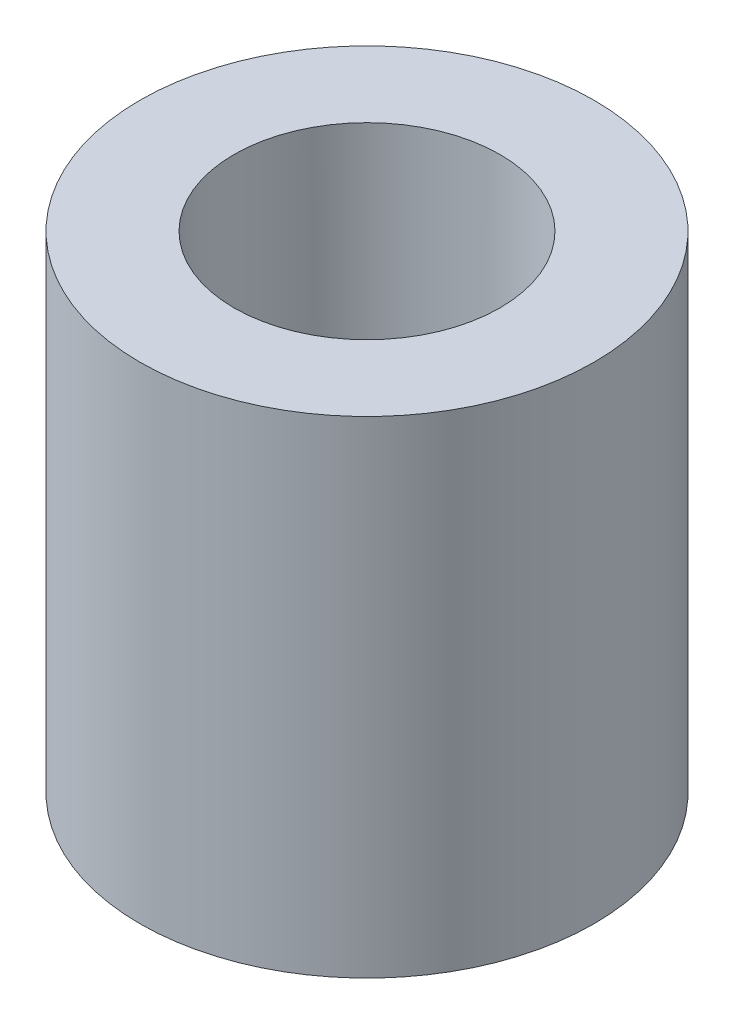
from build123d import *

# Parameters (mm, degrees)
SKETCH1_R           = 7
BOSS_EXTRUDE3_DEPTH = 15
SKETCH4_R           = 4.1
CUT_EXTRUDE1_DEPTH  = 11
SKETCH5_W           = 6.2
SKETCH5_H           = 6.2
CUT_EXTRUDE2_DEPTH  = 4


with BuildPart() as part:
    # Sketch1 → Boss-Extrude3 (new body)
    with BuildSketch(Plane(origin=(0, 0, 0), x_dir=(1, 0, 0), z_dir=(0, 1, 0))):
        with Locations(Location((0, 0, 0), (0, 0, 270))):  # turned: the seam where the file's is
            Circle(SKETCH1_R)
    extrude(amount=BOSS_EXTRUDE3_DEPTH)

    # Sketch4 → Cut-Extrude1 (cut)
    with BuildSketch(Plane(origin=(0, 15, 0), x_dir=(1, 0, 0), z_dir=(0, 1, 0))):
        with Locations(Location((0, 0, 0), (0, 0, 270))):  # turned: the seam where the file's is
            Circle(SKETCH4_R)
    extrude(amount=-CUT_EXTRUDE1_DEPTH, mode=Mode.SUBTRACT)

    # Sketch5 → Cut-Extrude2 (cut)
    with BuildSketch(Plane.XZ):
        Rectangle(SKETCH5_W, SKETCH5_H)
    extrude(amount=-CUT_EXTRUDE2_DEPTH, mode=Mode.SUBTRACT)


solid = part.part
